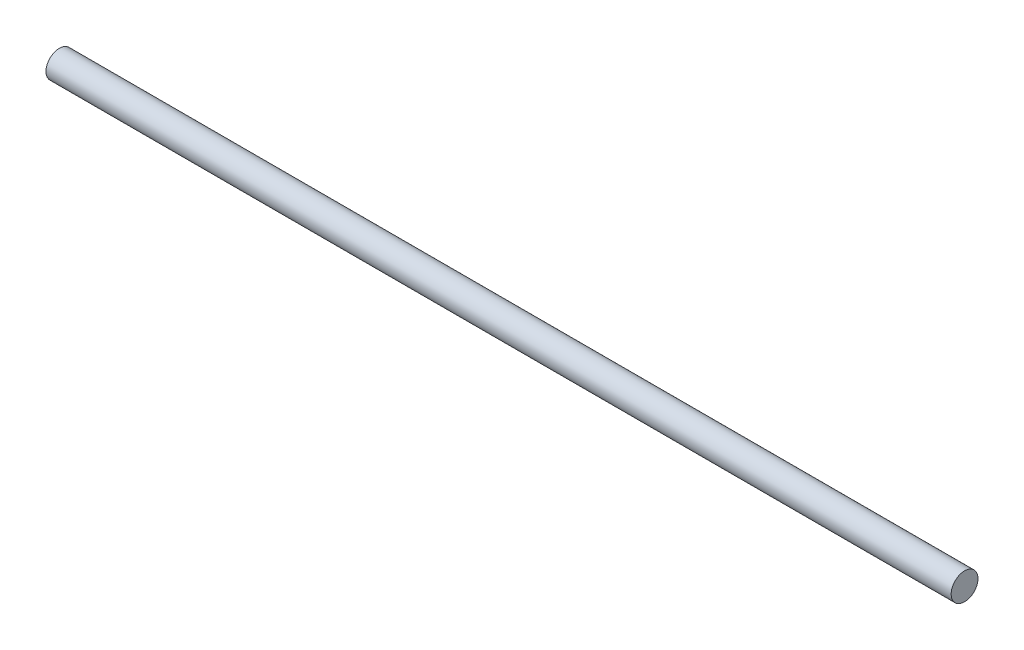
from build123d import *

# Parameters (mm, degrees)
SKETCH_1_R      = 1.75
EXTRUDE_1_DEPTH = 118


with BuildPart() as part:
    # Эскиз1 → Бобышка-Вытянуть1 (new body)
    with BuildSketch(Plane(origin=(0, 0, 0), x_dir=(0, 0, -1), z_dir=(1, 0, 0))):
        Circle(SKETCH_1_R)
    extrude(amount=EXTRUDE_1_DEPTH)


solid = part.part
